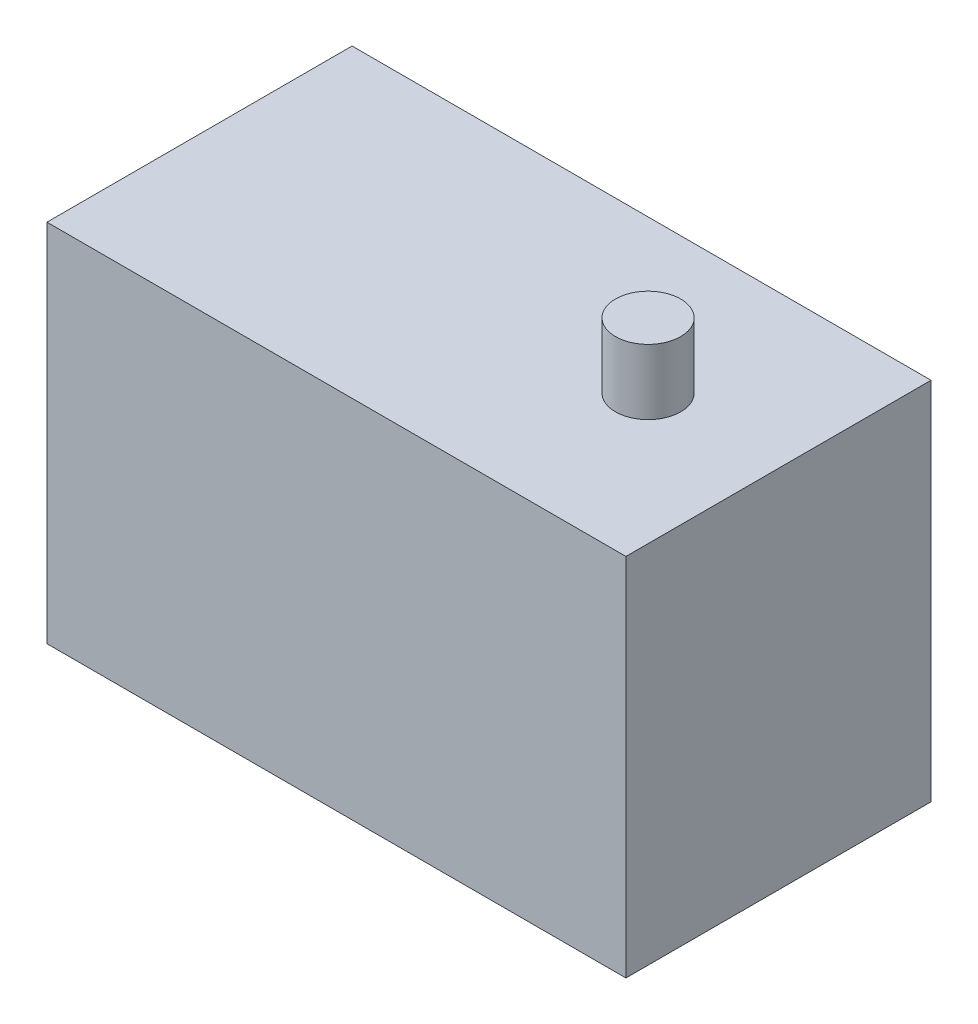
from build123d import *

# Parameters (mm, degrees)
SKETCH_1_W             = 44.4
SKETCH_1_H             = 23.4
EXTRUDE_1_DEPTH        = 28
SKETCH_2_R             = 2.5
EXTRUDE_2_DEPTH        = 5
PATTERN_LINEAR_1_COUNT = 2
PATTERN_LINEAR_1_PITCH = 33


with BuildPart() as part:
    # 草圖1 → 填料-伸長1 (new body)
    with BuildSketch(Plane(origin=(0, 0, 0), x_dir=(1, 0, 0), z_dir=(0, 1, 0))):
        with Locations((-19.947783251, 11.493103448)):
            Rectangle(SKETCH_1_W, SKETCH_1_H)
    extrude(amount=EXTRUDE_1_DEPTH)

    # 草圖2 → 填料-伸長2 (add)
    with BuildSketch(Plane(origin=(0, 0, 0), x_dir=(1, 0, 0), z_dir=(0, 1, 0))):
        with Locations((-7.747783251, 11.493103448)):
            Circle(SKETCH_2_R)
    extrude_2 = extrude(amount=-EXTRUDE_2_DEPTH)

    # 直線複製排列1: 填料-伸長2 ×2
    with Locations(*[(0, i * PATTERN_LINEAR_1_PITCH, 0) for i in range(1, PATTERN_LINEAR_1_COUNT)]):
        add(extrude_2)


solid = part.part
